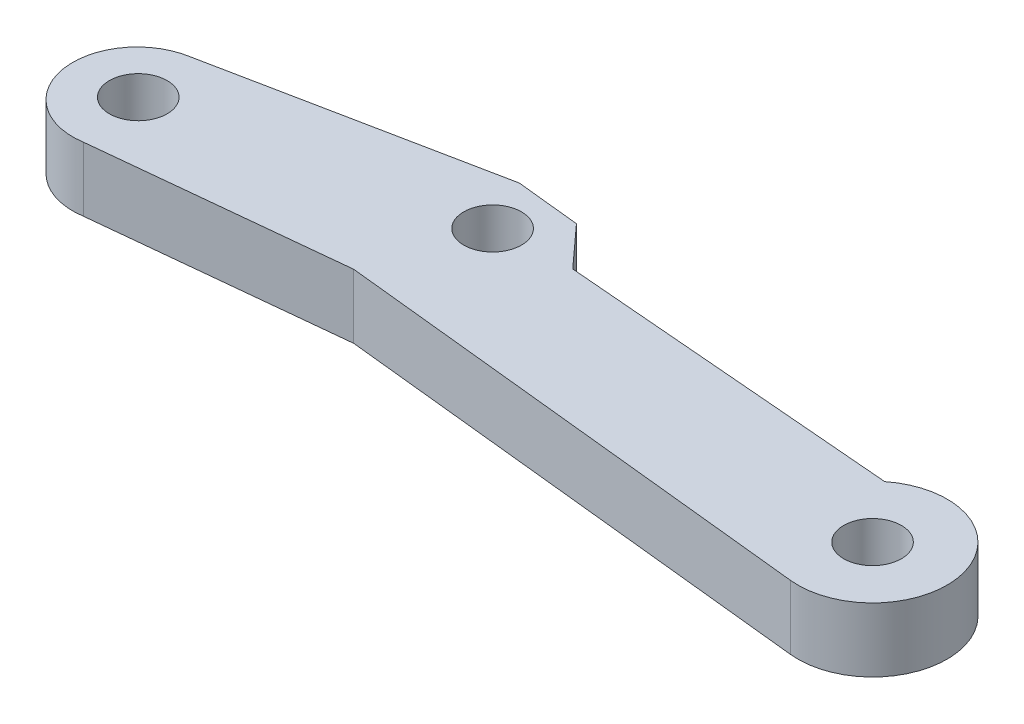
from build123d import *

# Parameters (mm, degrees)
BOSS_EXTRUDE1_DEPTH        = 5
F_4_5_4_5_DIAMETER_HOLE1_D = 4.5
F_4_5_4_5_DIAMETER_HOLE2_D = 4.5
CHAMFER3_SIZE              = 1.737611999
CHAMFER3_SIZE2             = 3.873994542
SKETCH18_R                 = 2.25
CUT_EXTRUDE1_DEPTH         = 10


with BuildPart() as part:
    # Sketch1 → Boss-Extrude1 (new body)
    with BuildSketch(Plane.XZ.offset(73)):
        with BuildLine():
            Line((47.401706558, 28.464616212), (51.486447787, 32.952250014))
            Line((51.486447787, 32.952250014), (77.985492495, 35.143180318))
            ThreePointArc((77.985492495, 35.143180318), (87.173153133, 38.077045167), (80.988712415, 45.477948081))
            Line((80.988712415, 45.477948081), (42.966330666, 41.501731436))
            Line((42.966330666, 41.501731436), (23.877297166, 43.453769804))
            ThreePointArc((23.877297166, 43.453769804), (18.123943846, 39.278307812), (22.299405838, 33.524954492))
            Line((22.299405838, 33.524954492), (47.401706558, 28.464616212))
        make_face()
    extrude(amount=-BOSS_EXTRUDE1_DEPTH)

    # Ø4.5 (4.5) Diameter Hole1 (through all)
    with Locations(Plane(origin=(0, -73, 0), x_dir=(-1, 0, 0), z_dir=(0, -1, 0))):
        with Locations((-45.629259616, -33.33886952)):
            Hole(F_4_5_4_5_DIAMETER_HOLE1_D / 2)

    # Ø4.5 (4.5) Diameter Hole2 (through all)
    with Locations(Plane(origin=(0, -73, 0), x_dir=(-1, 0, 0), z_dir=(0, -1, 0))):
        with Locations((-22.965684709, -38.284870865)):
            Hole(F_4_5_4_5_DIAMETER_HOLE2_D / 2)

    # Chamfer3
    chamfer3_edges = [part.edges().sort_by_distance(p)[0] for p in [
        (47.401706558, -70.5, 28.464616212),
    ]]
    chamfer3_side = [part.faces().sort_by_distance(p)[0] for p in [
        (49.444077173, -70.5, 30.708433113),
    ]]
    chamfer(chamfer3_edges, length=CHAMFER3_SIZE, length2=CHAMFER3_SIZE2, reference=chamfer3_side[0])

    # Sketch18 → Cut-Extrude1 (cut)
    with BuildSketch(Plane(origin=(0, -68, 0), x_dir=(1, 0, 0), z_dir=(0, 1, 0))):
        with Locations((81.593094218, -39.698575952)):
            Circle(SKETCH18_R)
    extrude(amount=-CUT_EXTRUDE1_DEPTH, mode=Mode.SUBTRACT)


solid = part.part
